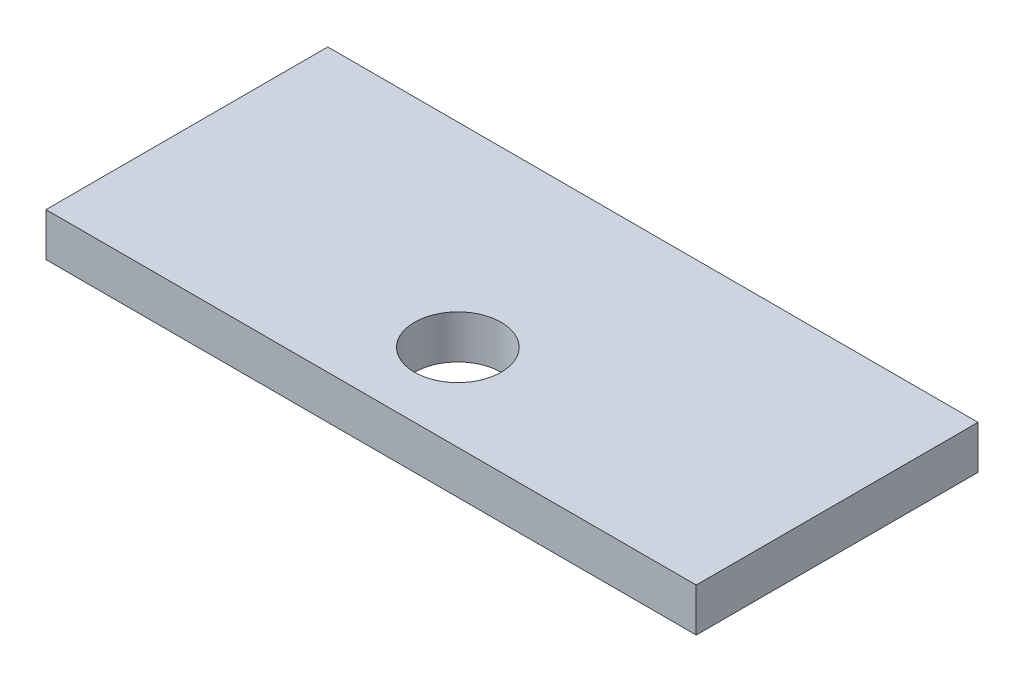
from build123d import *

# Parameters (mm, degrees)
SKETCH1_W               = 150
SKETCH1_H               = 65
BOSS_EXTRUDE1_DEPTH     = 10
SKETCH2_R               = 10
CUT_EXTRUDE2_DEPTH      = 11
CUT_EXTRUDE2_DEPTH_BACK = 1


with BuildPart() as part:
    # Sketch1 → Boss-Extrude1 (new body)
    with BuildSketch(Plane(origin=(0, 0, 0), x_dir=(1, 0, 0), z_dir=(0, 1, 0))):
        Rectangle(SKETCH1_W, SKETCH1_H)
    extrude(amount=BOSS_EXTRUDE1_DEPTH)

    # Sketch2 → Cut-Extrude2 (cut, two sides)
    with BuildSketch(Plane(origin=(0, 0, 0), x_dir=(1, 0, 0), z_dir=(0, 1, 0))) as cut_extrude2_sk:
        with Locations((0, -12.5)):
            Circle(SKETCH2_R)
    extrude(amount=CUT_EXTRUDE2_DEPTH, mode=Mode.SUBTRACT)
    extrude(cut_extrude2_sk.sketch, amount=-CUT_EXTRUDE2_DEPTH_BACK, mode=Mode.SUBTRACT)


solid = part.part
